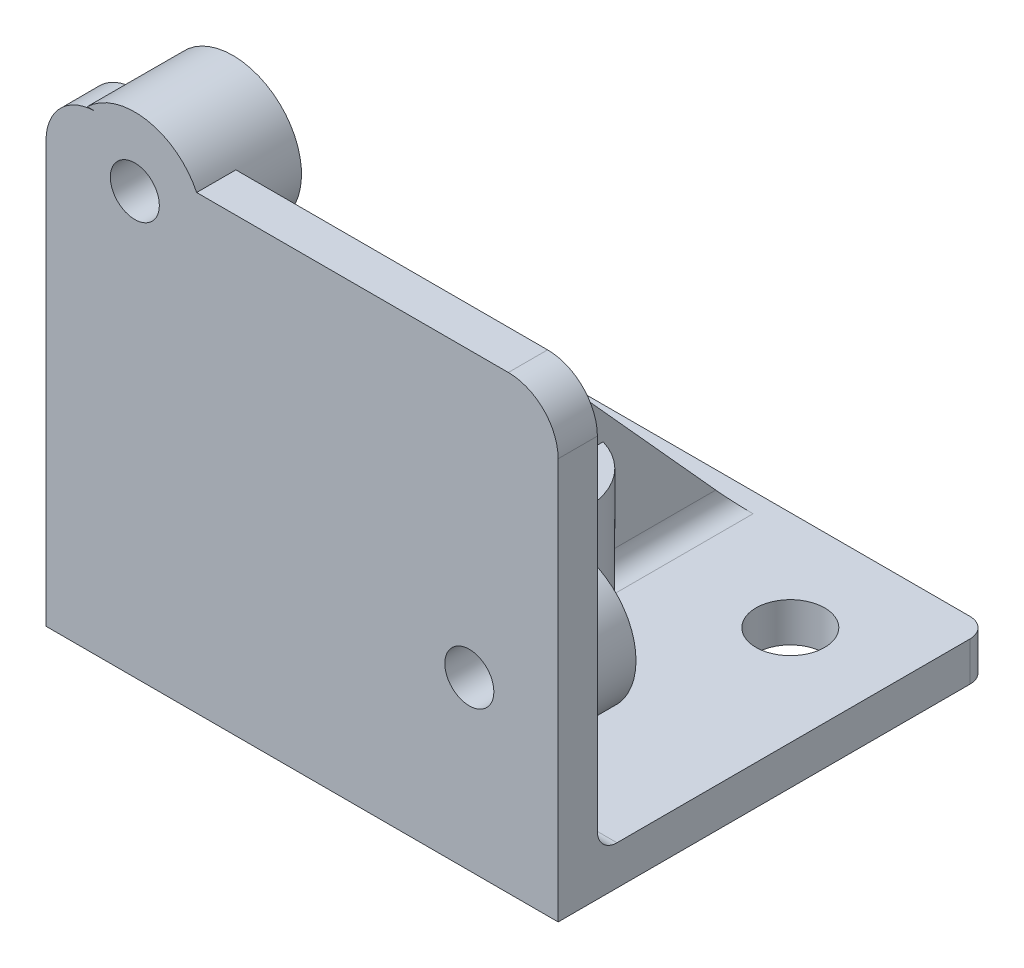
from build123d import *

# Parameters (mm, degrees)
SKETCH1_W                   = 26.12
SKETCH1_H                   = 24
SKETCH1_R                   = 1.25
BOSS_EXTRUDE1_DEPTH         = 2
SKETCH4_W                   = 26.12
SKETCH4_H                   = 2
BOSS_EXTRUDE4_DEPTH         = 20
FILLET2_R                   = 2.54
FILLET3_R                   = 1
FILLET4_R                   = 1
FILLET5_R                   = 1
BOSS_EXTRUDE5_DEPTH         = 2
BOSS_EXTRUDE6_DEPTH         = 1
FILLET10_R                  = 1
SKETCH15_R                  = 3.5
BOSS_EXTRUDE7_DEPTH         = 8
M3_5X0_6_TAPPED_HOLE1_D     = 2.9
M3_5X0_6_TAPPED_HOLE1_DEPTH = 10
M3_5X0_6_TAPPED_HOLE1_TIP   = 0.871247898
SKETCH19_R                  = 3.500559702
SKETCH19_R_2                = 1.27
BOSS_EXTRUDE8_DEPTH         = 3
CUT_EXTRUDE1_DEPTH          = 3
FILLET11_R                  = 2.54
SKETCH21_R                  = 1.75
CUT_EXTRUDE2_DEPTH          = 3


with BuildPart() as part:
    # Sketch1 → Boss-Extrude1 (new body)
    with BuildSketch(Plane.XY):
        with Locations((-15.65045068, 0.61225)):
            Rectangle(SKETCH1_W, SKETCH1_H)
        with Locations((-7.12045068, -2.85775)):
            Circle(SKETCH1_R, mode=Mode.SUBTRACT)
        with Locations((-24.18045068, 10.09225)):
            Circle(SKETCH1_R, mode=Mode.SUBTRACT)
    extrude(amount=BOSS_EXTRUDE1_DEPTH)

    # Sketch4 → Boss-Extrude4 (add)
    with BuildSketch(Plane(origin=(0, 0, 0), x_dir=(-1, 0, 0), z_dir=(0, 0, -1))):
        with Locations((15.65045068, -10.38775)):
            Rectangle(SKETCH4_W, SKETCH4_H)
    extrude(amount=BOSS_EXTRUDE4_DEPTH)

    # Fillet2
    fillet2_edges = [part.edges().sort_by_distance(p)[0] for p in [
        (-28.71045068, 12.61225, 1),
    ]]
    fillet(fillet2_edges, radius=FILLET2_R)

    # Fillet3
    fillet3_edges = [part.edges().sort_by_distance(p)[0] for p in [
        (-2.59045068, 12.61225, 1),
    ]]
    fillet(fillet3_edges, radius=FILLET3_R)

    # Fillet4
    fillet4_edges = [part.edges().sort_by_distance(p)[0] for p in [
        (-28.71045068, -10.38775, -20),
        (-2.59045068, -10.38775, -20),
    ]]
    fillet(fillet4_edges, radius=FILLET4_R)

    # Fillet5
    fillet5_edges = [part.edges().sort_by_distance(p)[0] for p in [
        (-15.65045068, -9.38775, 0),
    ]]
    fillet(fillet5_edges, radius=FILLET5_R)

    # Sketch7 → Boss-Extrude5 (add)
    with BuildSketch(Plane.XY.offset(2)):
        with BuildLine():
            Line((-26.610166349, 12.61225), (-21.750735012, 12.61225))
            ThreePointArc((-21.750735012, 12.61225), (-24.18045068, 13.592809702), (-26.610166349, 12.61225))
        make_face()
    extrude(amount=-BOSS_EXTRUDE5_DEPTH)

    # Sketch14 → Boss-Extrude6 (add, symmetric)
    with BuildSketch(Plane.ZY.offset(15.65045068)):
        Polygon((0, 11.61225), (-19, -9.38775), (0, -9.38775), (0, 11.544281389), align=None)
    extrude(amount=BOSS_EXTRUDE6_DEPTH, both=True)

    # Fillet10
    fillet10_edges = [part.edges().sort_by_distance(p)[0] for p in [
        (-14.65045068, -9.094856781, -0.292893219),
        (-16.65045068, -9.094856781, -0.292893219),
        (-14.65045068, 1.61225, 0),
        (-16.65045068, 1.61225, 0),
        (-16.65045068, -9.38775, -10),
        (-14.65045068, -9.38775, -10),
    ]]
    fillet(fillet10_edges, radius=FILLET10_R)

    # Sketch15 → Boss-Extrude7 (add)
    with BuildSketch(Plane.XZ.offset(11.38775)):
        with Locations((-15.65045068, -9)):
            Circle(SKETCH15_R)
    extrude(amount=-BOSS_EXTRUDE7_DEPTH)

    # M3.5x0.6 Tapped Hole1
    with Locations(Plane(origin=(0, -11.38775, 0), x_dir=(-1, 0, 0), z_dir=(0, -1, 0))):
        with Locations((15.65045068, 9)):
            Hole(M3_5X0_6_TAPPED_HOLE1_D / 2, depth=M3_5X0_6_TAPPED_HOLE1_DEPTH)
            with Locations((0, 0, -(M3_5X0_6_TAPPED_HOLE1_DEPTH + M3_5X0_6_TAPPED_HOLE1_TIP / 2))):  # 118° drill point
                Cone(0, M3_5X0_6_TAPPED_HOLE1_D / 2, M3_5X0_6_TAPPED_HOLE1_TIP, mode=Mode.SUBTRACT)

    # Sketch19 → Boss-Extrude8 (add)
    with BuildSketch(Plane(origin=(0, 0, 0), x_dir=(-1, 0, 0), z_dir=(0, 0, -1))):
        with Locations((7.12045068, -2.85775)):
            Circle(SKETCH19_R)
        with Locations((7.12045068, -2.85775)):
            Circle(SKETCH19_R_2, mode=Mode.SUBTRACT)
        with Locations((24.18045068, 10.09225)):
            Circle(SKETCH19_R)
        with Locations((24.18045068, 10.09225)):
            Circle(SKETCH19_R_2, mode=Mode.SUBTRACT)
    extrude(amount=BOSS_EXTRUDE8_DEPTH)

    # Sketch20 → Cut-Extrude1 (cut, through all)
    with BuildSketch(Plane(origin=(0, 0, 0), x_dir=(-1, 0, 0), z_dir=(0, 0, -1))):
        with BuildLine():
            Line((21.027116218, 11.61225), (2.59045068, 11.61225))
            Line((2.59045068, 11.61225), (2.59045068, 12.61225))
            Line((2.59045068, 12.61225), (21.750735012, 12.61225))
            ThreePointArc((21.750735012, 12.61225), (21.344500718, 12.144396691), (21.027116218, 11.61225))
        make_face()
    extrude(amount=-CUT_EXTRUDE1_DEPTH, mode=Mode.SUBTRACT)

    # Fillet11
    fillet11_edges = [part.edges().sort_by_distance(p)[0] for p in [
        (-2.59045068, 11.61225, 1),
    ]]
    fillet(fillet11_edges, radius=FILLET11_R)

    # Sketch21 → Cut-Extrude2 (cut, through all)
    with BuildSketch(Plane(origin=(0, -9.38775, 0), x_dir=(1, 0, 0), z_dir=(0, 1, 0))):
        with Locations((-23.63045068, 14.92)):
            Circle(SKETCH21_R)
        with Locations((-7.67045068, 14.92)):
            Circle(SKETCH21_R)
    extrude(amount=-CUT_EXTRUDE2_DEPTH, mode=Mode.SUBTRACT)


solid = part.part
